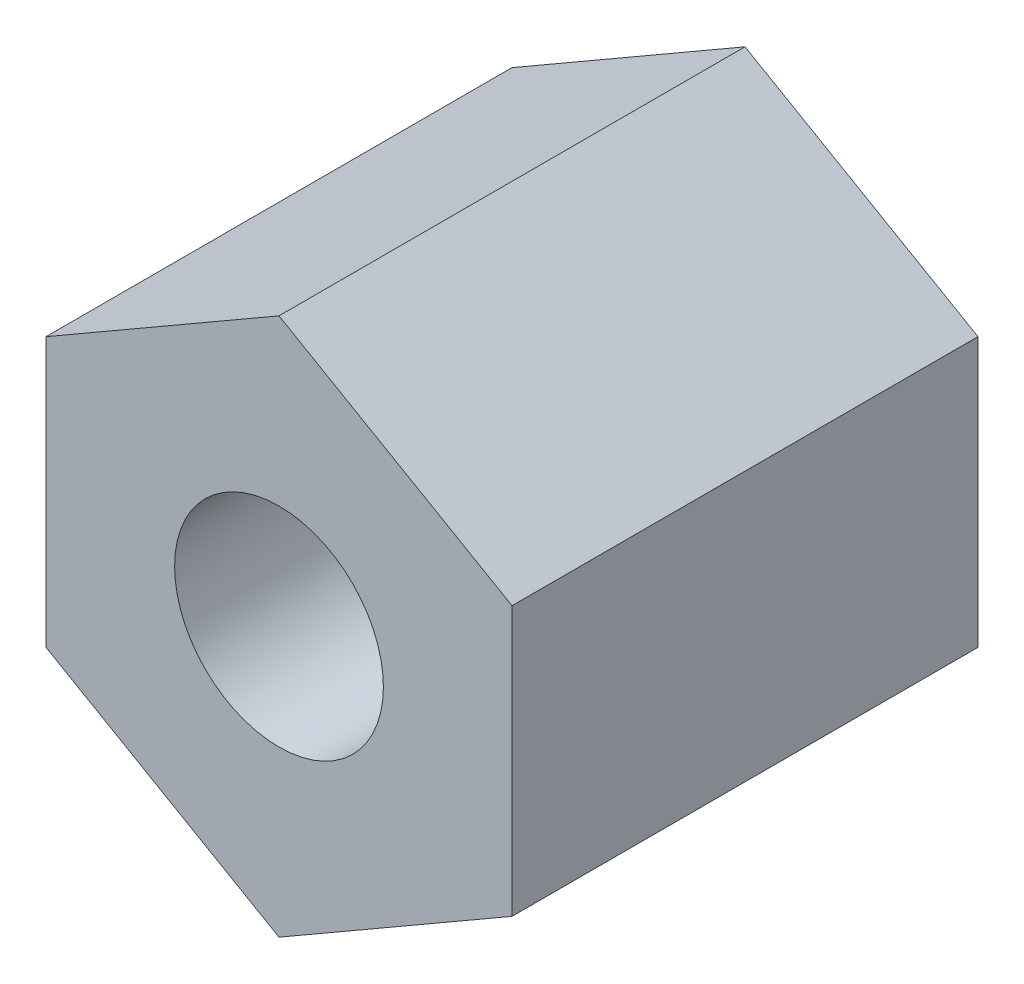
from build123d import *

# Parameters (mm, degrees)
SKETCH2_R           = 1.4224
BOSS_EXTRUDE1_DEPTH = 6.35


with BuildPart() as part:
    # Sketch2 → Boss-Extrude1 (new body)
    with BuildSketch(Plane.XY):
        Polygon((0, 3.666174209), (3.175, 1.833087105), (3.175, -1.833087105), (0, -3.666174209), (-3.175, -1.833087105), (-3.175, 1.833087105), align=None)
        Circle(SKETCH2_R, mode=Mode.SUBTRACT)
    extrude(amount=BOSS_EXTRUDE1_DEPTH)


solid = part.part
